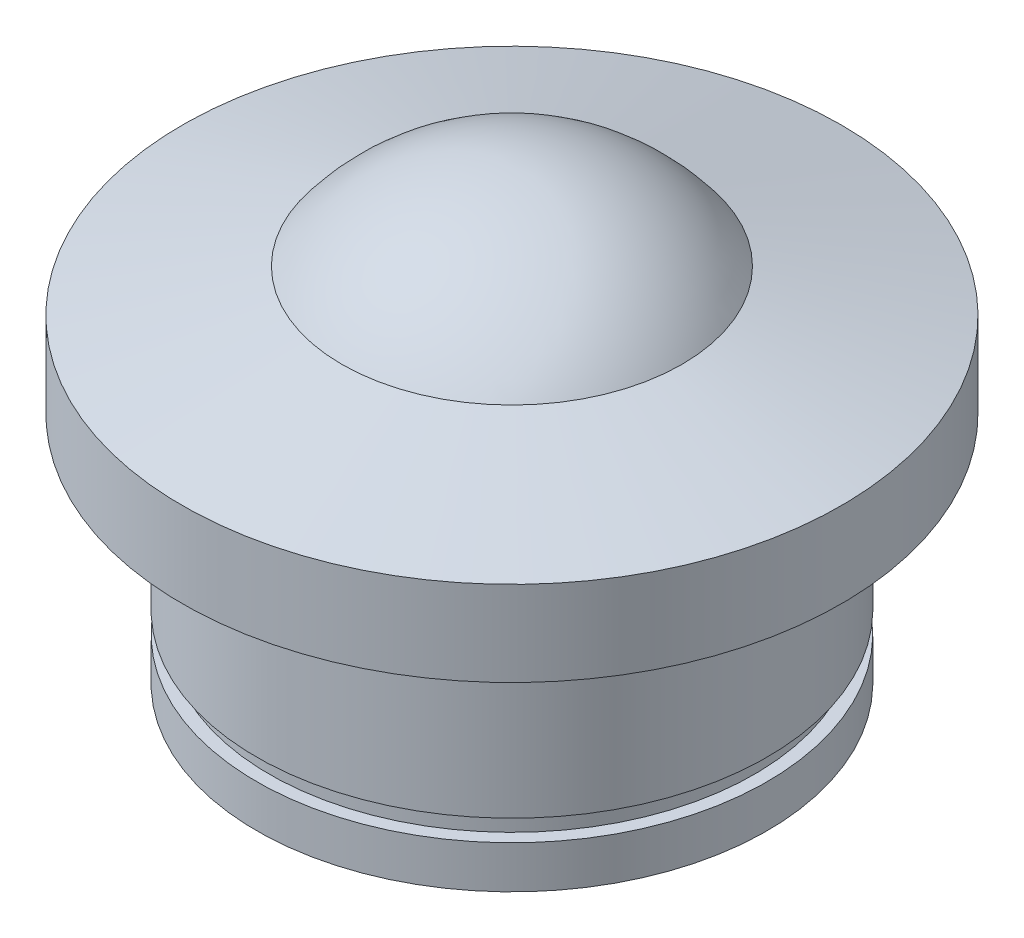
from build123d import *


with BuildPart() as part:
    # Esquisse1 → Révolution1 (revolve)
    with BuildSketch(Plane.XY):
        with BuildLine():
            Line((0, 0), (12, 0))
            Line((12, 0), (12, 2))
            Line((12, 2), (11.4, 2))
            Line((11.4, 2), (11.4, 3))
            Line((11.4, 3), (12, 3))
            Line((12, 3), (12, 11))
            Line((12, 11), (15.5, 11))
            Line((15.5, 11), (15.5, 15))
            Line((15.5, 15), (8, 17))
            ThreePointArc((8, 17), (4.472135955, 19.94427191), (0, 21))
            Line((0, 21), (0, 0))
        make_face()
    revolve(axis=Axis((0, 0, 0), (0, 1, 0)))


solid = part.part
